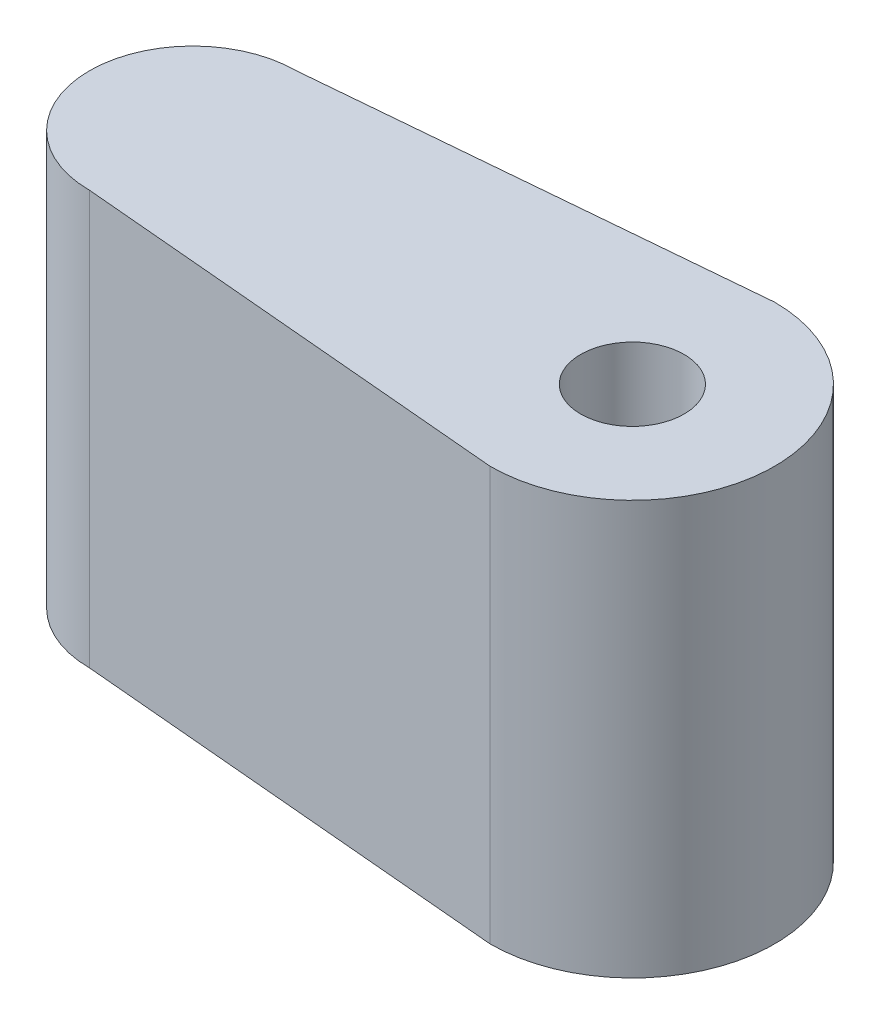
from build123d import *

# Parameters (mm, degrees)
SKETCH1_R           = 1
BOSS_EXTRUDE1_DEPTH = 8
SKETCH2_R           = 1
CUT_EXTRUDE1_DEPTH  = 8


with BuildPart() as part:
    # Sketch1 → Boss-Extrude1 (new body)
    with BuildSketch(Plane(origin=(0, 0, 0), x_dir=(1, 0, 0), z_dir=(0, 1, 0))):
        with BuildLine():
            Line((-0.481545064, 2.70751073), (-8.5, 2))
            ThreePointArc((-8.5, 2), (-10.5, 0), (-8.5, -2))
            Line((-8.5, -2), (-0.481545064, -2.70751073))
            Line((-0.481545064, -2.70751073), (0, -2.75))
            ThreePointArc((0, -2.75), (2.75, 0), (0, 2.75))
            Line((0, 2.75), (-0.481545064, 2.70751073))
        make_face()
        Circle(SKETCH1_R, mode=Mode.SUBTRACT)
    extrude(amount=BOSS_EXTRUDE1_DEPTH)

    # Sketch2 → Cut-Extrude1 (cut)
    with BuildSketch(Plane.ZY.offset(10.5)):
        with Locations((0, 4)):
            Circle(SKETCH2_R)
    extrude(amount=-CUT_EXTRUDE1_DEPTH, mode=Mode.SUBTRACT)


solid = part.part
